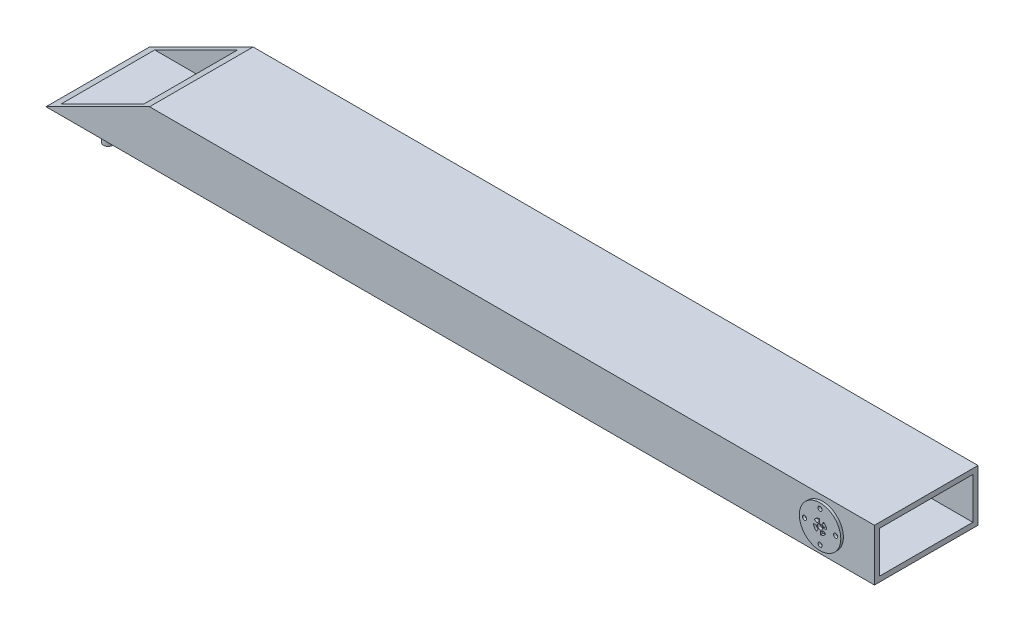
from build123d import *

# Parameters (mm, degrees)
SKETCH2_R               = 20.25
BOSS_EXTRUDE1_DEPTH     = 200
SKETCH3_R               = 40
SKETCH3_R_2             = 5
SKETCH3_R_3             = 4
BOSS_EXTRUDE2_DEPTH     = 5
CUT_EXTRUDE5_DEPTH      = 6
CUT_EXTRUDE5_DEPTH_BACK = 201
SKETCH5_W               = 180
SKETCH5_H               = 80
CUT_EXTRUDE6_DEPTH      = 1601
SKETCH6_R               = 9
BOSS_EXTRUDE3_DEPTH     = 60


with BuildPart() as part:
    # Sketch2 → Boss-Extrude1 (new body)
    with BuildSketch(Plane.XY):
        Polygon((100, 0), (100, -50), (-1500, -50), (-1300, 50), (100, 50), align=None)
        Circle(SKETCH2_R, mode=Mode.SUBTRACT)
    extrude(amount=BOSS_EXTRUDE1_DEPTH)

    # Sketch3 → Boss-Extrude2 (add)
    with BuildSketch(Plane.XY.offset(200)):
        Circle(SKETCH3_R)
        Circle(SKETCH3_R_2, mode=Mode.SUBTRACT)
        with Locations((-30, 0)):
            Circle(SKETCH3_R_3, mode=Mode.SUBTRACT)
        with Locations((0, 30)):
            Circle(SKETCH3_R_3, mode=Mode.SUBTRACT)
        with Locations((30, 0)):
            Circle(SKETCH3_R_3, mode=Mode.SUBTRACT)
        with Locations((0, -30)):
            Circle(SKETCH3_R_3, mode=Mode.SUBTRACT)
    extrude(amount=BOSS_EXTRUDE2_DEPTH)

    # Sketch4 → Cut-Extrude5 (cut, two sides)
    with BuildSketch(Plane.XY.offset(200)) as cut_extrude5_sk:
        with BuildLine():
            Line((-0.95, 6.801251402), (-0.95, 12.900595285))
            ThreePointArc((-0.95, 12.900595285), (-6.767664084, 11.023909541), (-11.07399335, 6.685396773))
            Line((-11.07399335, 6.685396773), (-5.777899362, 3.711522544))
            ThreePointArc((-5.777899362, 3.711522544), (-3.701724404, 5.784181625), (-0.95, 6.801251402))
        make_face()
        with BuildLine():
            Line((6.801251402, 0.95), (12.900595285, 0.95))
            ThreePointArc((12.900595285, 0.95), (11.023909541, 6.767664084), (6.685396773, 11.07399335))
            Line((6.685396773, 11.07399335), (3.711522544, 5.777899362))
            ThreePointArc((3.711522544, 5.777899362), (5.784181625, 3.701724404), (6.801251402, 0.95))
        make_face()
        with BuildLine():
            Line((0.95, -6.801251402), (0.95, -12.900595285))
            ThreePointArc((0.95, -12.900595285), (6.767664084, -11.023909541), (11.07399335, -6.685396773))
            Line((11.07399335, -6.685396773), (5.777899362, -3.711522544))
            ThreePointArc((5.777899362, -3.711522544), (3.701724404, -5.784181625), (0.95, -6.801251402))
        make_face()
        with BuildLine():
            Line((-6.801251402, -0.95), (-12.900595285, -0.95))
            ThreePointArc((-12.900595285, -0.95), (-11.023909541, -6.767664084), (-6.685396773, -11.07399335))
            Line((-6.685396773, -11.07399335), (-3.711522544, -5.777899362))
            ThreePointArc((-3.711522544, -5.777899362), (-5.784181625, -3.701724404), (-6.801251402, -0.95))
        make_face()
    extrude(amount=CUT_EXTRUDE5_DEPTH, mode=Mode.SUBTRACT)
    extrude(cut_extrude5_sk.sketch, amount=-CUT_EXTRUDE5_DEPTH_BACK, mode=Mode.SUBTRACT)

    # Sketch5 → Cut-Extrude6 (cut, through all)
    with BuildSketch(Plane(origin=(100, 0, 0), x_dir=(0, 0, -1), z_dir=(1, 0, 0))):
        with Locations((-100, 0)):
            Rectangle(SKETCH5_W, SKETCH5_H)
    extrude(amount=-CUT_EXTRUDE6_DEPTH, mode=Mode.SUBTRACT)

    # Sketch6 → Boss-Extrude3 (add)
    with BuildSketch(Plane(origin=(0, -40, 0), x_dir=(1, 0, 0), z_dir=(0, 1, 0))):
        with Locations((-1430, -150)):
            Circle(SKETCH6_R)
        with Locations((-1430, -50)):
            Circle(SKETCH6_R)
    extrude(amount=-BOSS_EXTRUDE3_DEPTH)


solid = part.part
